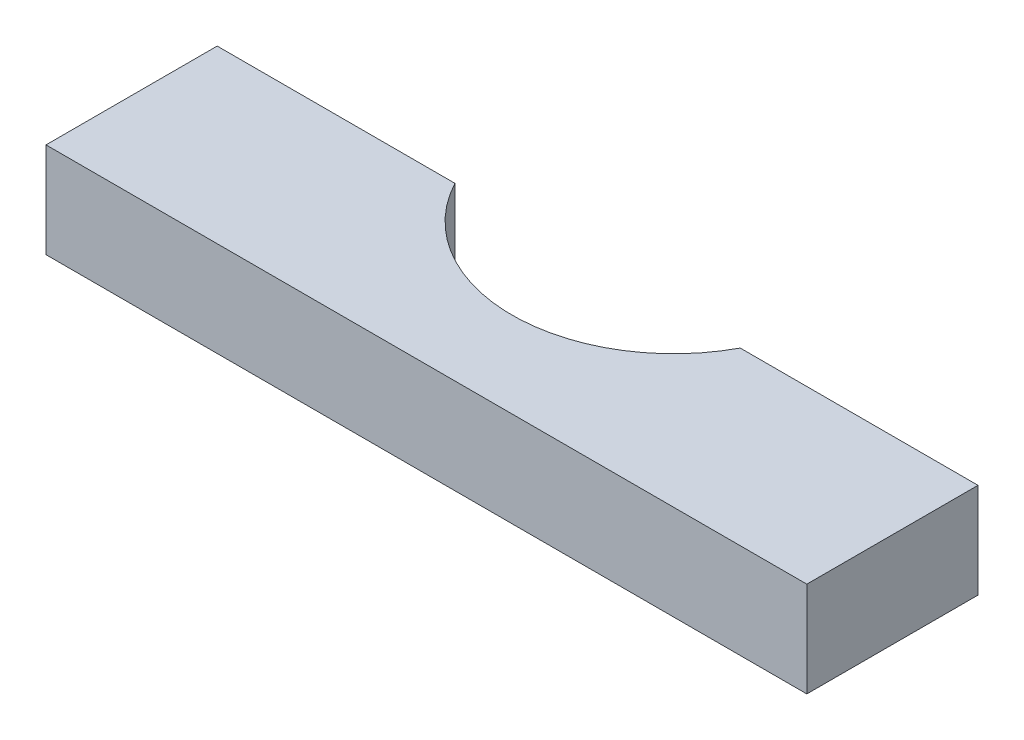
from build123d import *

# Parameters (mm, degrees)
SKETCH1_W           = 50.8
SKETCH1_H           = 11.43
BOSS_EXTRUDE1_DEPTH = 6.35
CUT_EXTRUDE1_DEPTH  = 7.35


with BuildPart() as part:
    # Sketch1 → Boss-Extrude1 (new body)
    with BuildSketch(Plane(origin=(0, 0, 0), x_dir=(1, 0, 0), z_dir=(0, 1, 0))):
        Rectangle(SKETCH1_W, SKETCH1_H)
    extrude(amount=BOSS_EXTRUDE1_DEPTH)

    # Sketch2 → Cut-Extrude1 (cut, through all)
    with BuildSketch(Plane(origin=(0, 6.35, 0), x_dir=(1, 0, 0), z_dir=(0, 1, 0))):
        with BuildLine():
            Line((-9.525, 5.715), (9.525, 5.715))
            ThreePointArc((9.525, 5.715), (0, 0), (-9.525, 5.715))
        make_face()
    extrude(amount=-CUT_EXTRUDE1_DEPTH, mode=Mode.SUBTRACT)


solid = part.part
